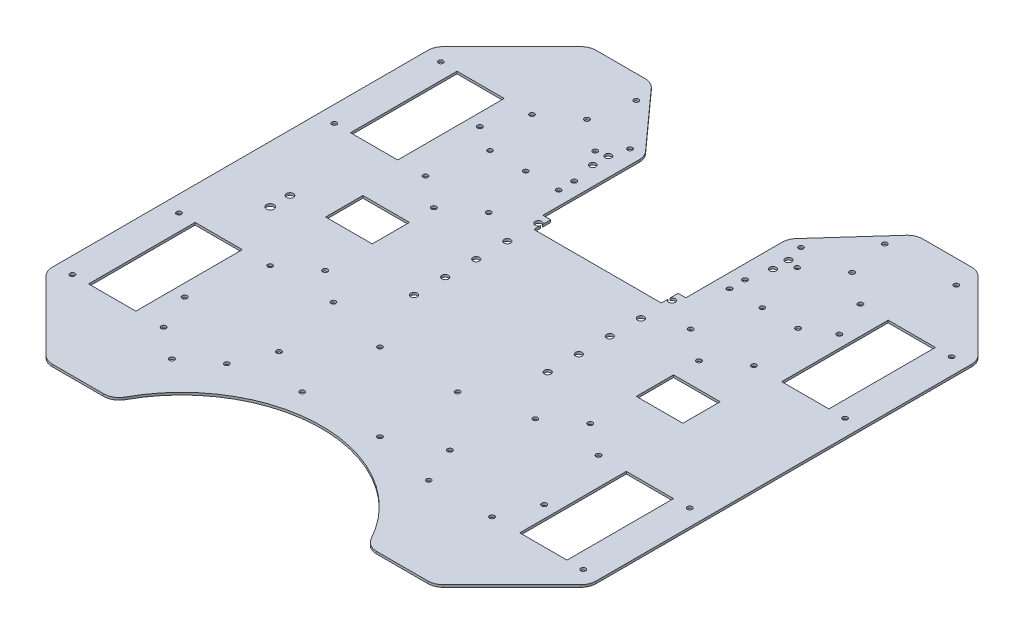
from build123d import *

# Parameters (mm, degrees)
SKETCH_1_R          = 1.55
SKETCH_1_W          = 30.4
SKETCH_1_H          = 68.58
SKETCH_1_R_2        = 2.5
SKETCH_1_R_3        = 2.205
SKETCH_1_R_4        = 2.05
EXTRUDE_1_DEPTH     = 1.5
FILLET_1_R          = 10
FILLET_2_R          = 10
FILLET_3_R          = 10
SKETCH_2_W          = 80
SKETCH_2_H          = 29.628438218
CUT_EXTRUDE_1_DEPTH = 10
SKETCH_3_W          = 30
SKETCH_3_H          = 24
CUT_EXTRUDE_2_DEPTH = 10
SKETCH_1_4_R        = 2.1
CUT_EXTRUDE_3_DEPTH = 10
SKETCH_5_W          = 92
SKETCH_5_H          = 68.528071536
CUT_EXTRUDE_4_DEPTH = 4
SKETCH_6_W          = 82
SKETCH_6_H          = 10.813051581
CUT_EXTRUDE_5_DEPTH = 10
FILLET_4_R          = 10
SKETCH_1_5_R        = 1.6
CUT_EXTRUDE_7_DEPTH = 10
SKETCH_1_6_R        = 1.6
CUT_EXTRUDE_8_DEPTH = 10


with BuildPart() as part:
    # 草图1 → 凸台-拉伸1 (new body)
    with BuildSketch(Plane(origin=(0, 0, 0), x_dir=(1, 0, 0), z_dir=(0, 1, 0))):
        with BuildLine():
            Line((-85, 175), (-125, 175))
            Line((-125, 175), (-175, 125))
            Line((-175, 125), (-175, -125))
            Line((-175, -125), (-125, -175))
            Line((-125, -175), (-81.710313025, -175))
            ThreePointArc((-81.710313025, -175), (0, -122.728301649), (81.710313025, -175))
            Line((81.710313025, -175), (125, -175))
            Line((125, -175), (175, -125))
            Line((175, -125), (175, 125))
            Line((175, 125), (125, 175))
            Line((125, 175), (85, 175))
            Line((85, 175), (40, 125))
            Line((40, 125), (40, 85))
            Line((40, 85), (-40, 85))
            Line((-40, 85), (-40, 125))
            Line((-40, 125), (-85, 175))
        make_face()
        with Locations((-164.434, -118.58)):
            Circle(SKETCH_1_R, mode=Mode.SUBTRACT)
        with Locations((-105.72, -118.58)):
            Circle(SKETCH_1_R, mode=Mode.SUBTRACT)
        with Locations((-65, -118.58)):
            Circle(SKETCH_1_R, mode=Mode.SUBTRACT)
        with Locations((-25, -110)):
            Circle(SKETCH_1_R, mode=Mode.SUBTRACT)
        with Locations((-138.794, -84.29)):
            Rectangle(SKETCH_1_W, SKETCH_1_H, mode=Mode.SUBTRACT)
        with Locations((-164.434, -50)):
            Circle(SKETCH_1_R, mode=Mode.SUBTRACT)
        with Locations((-105.72, -50)):
            Circle(SKETCH_1_R, mode=Mode.SUBTRACT)
        with Locations((-138.472923085, -17.157455951)):
            Circle(SKETCH_1_R_2, mode=Mode.SUBTRACT)
        with Locations((-138.472923085, -4.457455951)):
            Circle(SKETCH_1_R_3, mode=Mode.SUBTRACT)
        with Locations((-65, -50)):
            Circle(SKETCH_1_R, mode=Mode.SUBTRACT)
        with Locations((-25, -60)):
            Circle(SKETCH_1_R, mode=Mode.SUBTRACT)
        with Locations((25, -110)):
            Circle(SKETCH_1_R, mode=Mode.SUBTRACT)
        with Locations((65, -118.58)):
            Circle(SKETCH_1_R, mode=Mode.SUBTRACT)
        with Locations((105.72, -118.58)):
            Circle(SKETCH_1_R, mode=Mode.SUBTRACT)
        with Locations((164.434, -118.58)):
            Circle(SKETCH_1_R, mode=Mode.SUBTRACT)
        with Locations((25, -60)):
            Circle(SKETCH_1_R, mode=Mode.SUBTRACT)
        with Locations((65, -50)):
            Circle(SKETCH_1_R, mode=Mode.SUBTRACT)
        with Locations((105.72, -50)):
            Circle(SKETCH_1_R, mode=Mode.SUBTRACT)
        with Locations((138.794, -84.29)):
            Rectangle(SKETCH_1_W, SKETCH_1_H, mode=Mode.SUBTRACT)
        with Locations((164.434, -50)):
            Circle(SKETCH_1_R, mode=Mode.SUBTRACT)
        with Locations((-164.434, 50)):
            Circle(SKETCH_1_R, mode=Mode.SUBTRACT)
        with Locations((-138.794, 84.29)):
            Rectangle(SKETCH_1_W, SKETCH_1_H, mode=Mode.SUBTRACT)
        with Locations((-105.72, 50)):
            Circle(SKETCH_1_R, mode=Mode.SUBTRACT)
        with Locations((-99.147504451, 85)):
            Circle(SKETCH_1_R, mode=Mode.SUBTRACT)
        with Locations((-65, 50)):
            Circle(SKETCH_1_R, mode=Mode.SUBTRACT)
        with Locations((-76.13554325, 85)):
            Circle(SKETCH_1_R, mode=Mode.SUBTRACT)
        with Locations((-55, 85)):
            Circle(SKETCH_1_R, mode=Mode.SUBTRACT)
        with Locations((-164.434, 118.58)):
            Circle(SKETCH_1_R, mode=Mode.SUBTRACT)
        with Locations((-105.72, 118.58)):
            Circle(SKETCH_1_R, mode=Mode.SUBTRACT)
        with Locations((-58, 110)):
            Circle(SKETCH_1_R_4, mode=Mode.SUBTRACT)
        with Locations((-65, 118.58)):
            Circle(SKETCH_1_R, mode=Mode.SUBTRACT)
        with Locations((-58, 120)):
            Circle(SKETCH_1_R_4, mode=Mode.SUBTRACT)
        with Locations((-55, 131)):
            Circle(SKETCH_1_R, mode=Mode.SUBTRACT)
        with Locations((-43, 110)):
            Circle(SKETCH_1_R_4, mode=Mode.SUBTRACT)
        with Locations((-43, 120)):
            Circle(SKETCH_1_R_4, mode=Mode.SUBTRACT)
        with Locations((-80, 160)):
            Circle(SKETCH_1_R, mode=Mode.SUBTRACT)
        with Locations((65, 50)):
            Circle(SKETCH_1_R, mode=Mode.SUBTRACT)
        with Locations((55, 85)):
            Circle(SKETCH_1_R, mode=Mode.SUBTRACT)
        with Locations((76.13554325, 85)):
            Circle(SKETCH_1_R, mode=Mode.SUBTRACT)
        with Locations((105.72, 50)):
            Circle(SKETCH_1_R, mode=Mode.SUBTRACT)
        with Locations((99.147504451, 85)):
            Circle(SKETCH_1_R, mode=Mode.SUBTRACT)
        with Locations((164.434, 50)):
            Circle(SKETCH_1_R, mode=Mode.SUBTRACT)
        with Locations((138.794, 84.29)):
            Rectangle(SKETCH_1_W, SKETCH_1_H, mode=Mode.SUBTRACT)
        with Locations((43, 110)):
            Circle(SKETCH_1_R_4, mode=Mode.SUBTRACT)
        with Locations((43, 120)):
            Circle(SKETCH_1_R_4, mode=Mode.SUBTRACT)
        with Locations((58, 110)):
            Circle(SKETCH_1_R_4, mode=Mode.SUBTRACT)
        with Locations((58, 120)):
            Circle(SKETCH_1_R_4, mode=Mode.SUBTRACT)
        with Locations((65, 118.58)):
            Circle(SKETCH_1_R, mode=Mode.SUBTRACT)
        with Locations((55, 131)):
            Circle(SKETCH_1_R, mode=Mode.SUBTRACT)
        with Locations((80, 160)):
            Circle(SKETCH_1_R, mode=Mode.SUBTRACT)
        with Locations((105.72, 118.58)):
            Circle(SKETCH_1_R, mode=Mode.SUBTRACT)
        with Locations((164.434, 118.58)):
            Circle(SKETCH_1_R, mode=Mode.SUBTRACT)
        with Locations((126, 160)):
            Circle(SKETCH_1_R, mode=Mode.SUBTRACT)
    extrude(amount=EXTRUDE_1_DEPTH)

    # 圆角1
    fillet_1_edges = [part.edges().sort_by_distance(p)[0] for p in [
        (-40, 0.75, -125),
    ]]
    fillet(fillet_1_edges, radius=FILLET_1_R)

    # 圆角2
    fillet_2_edges = [part.edges().sort_by_distance(p)[0] for p in [
        (40, 0.75, -125),
    ]]
    fillet(fillet_2_edges, radius=FILLET_2_R)

    # 圆角3
    fillet_3_edges = [part.edges().sort_by_distance(p)[0] for p in [
        (-85, 0.75, -175),
        (85, 0.75, -175),
        (125, 0.75, -175),
        (175, 0.75, -125),
        (175, 0.75, 125),
        (125, 0.75, 175),
        (81.710313025, 0.75, 175),
        (-81.710313025, 0.75, 175),
        (-125, 0.75, 175),
        (-175, 0.75, 125),
        (-175, 0.75, -125),
        (-125, 0.75, -175),
    ]]
    fillet(fillet_3_edges, radius=FILLET_3_R)

    # 草图2 → 切除-拉伸1 (cut)
    with BuildSketch(Plane(origin=(0, 1.5, 0), x_dir=(1, 0, 0), z_dir=(0, 1, 0))):
        with Locations((0, 70.185780891)):
            Rectangle(SKETCH_2_W, SKETCH_2_H)
    extrude(amount=-CUT_EXTRUDE_1_DEPTH, mode=Mode.SUBTRACT)

    # 草图3 → 切除-拉伸2 (cut)
    with BuildSketch(Plane(origin=(0, 1.5, 0), x_dir=(1, 0, 0), z_dir=(0, 1, 0))):
        with Locations((-100, 7)):
            Rectangle(SKETCH_3_W, SKETCH_3_H)
        with Locations((100, 7)):
            Rectangle(SKETCH_3_W, SKETCH_3_H)
    extrude(amount=-CUT_EXTRUDE_2_DEPTH, mode=Mode.SUBTRACT)

    # 草图1<4> → 切除-拉伸3 (cut)
    with BuildSketch(Plane(origin=(0, 0, 0), x_dir=(1, 0, 0), z_dir=(0, 1, 0))):
        with Locations((43, -20)):
            Circle(SKETCH_1_4_R)
        with Locations((43, 0)):
            Circle(SKETCH_1_4_R)
        with Locations((43, 20)):
            Circle(SKETCH_1_4_R)
        with Locations((43, 40)):
            Circle(SKETCH_1_4_R)
        with Locations((43, 60)):
            Circle(SKETCH_1_4_R)
        with Locations((-43, -20)):
            Circle(SKETCH_1_4_R)
        with Locations((-43, 0)):
            Circle(SKETCH_1_4_R)
        with Locations((-43, 20)):
            Circle(SKETCH_1_4_R)
        with Locations((-43, 40)):
            Circle(SKETCH_1_4_R)
        with Locations((-43, 60)):
            Circle(SKETCH_1_4_R)
    extrude(amount=CUT_EXTRUDE_3_DEPTH, mode=Mode.SUBTRACT)

    # 草图5 → 切除-拉伸4 (cut)
    with BuildSketch(Plane.XZ):
        with Locations((0, -100.191724722)):
            Rectangle(SKETCH_5_W, SKETCH_5_H)
    extrude(amount=-CUT_EXTRUDE_4_DEPTH, mode=Mode.SUBTRACT)

    # 草图6 → 切除-拉伸5 (cut)
    with BuildSketch(Plane(origin=(0, 1.5, 0), x_dir=(1, 0, 0), z_dir=(0, 1, 0))):
        with Locations((0, 60.521163164)):
            Rectangle(SKETCH_6_W, SKETCH_6_H)
    extrude(amount=-CUT_EXTRUDE_5_DEPTH, mode=Mode.SUBTRACT)

    # 圆角4
    fillet_4_edges = [part.edges().sort_by_distance(p)[0] for p in [
        (46, 0.75, -131.666666667),
        (-46, 0.75, -131.666666667),
    ]]
    fillet(fillet_4_edges, radius=FILLET_4_R)

    # 草图1<5> → 切除-拉伸7 (cut)
    with BuildSketch(Plane(origin=(0, 0, 0), x_dir=(1, 0, 0), z_dir=(0, 1, 0))):
        with Locations((-85.36, -35)):
            Circle(SKETCH_1_5_R)
        with Locations((-85.36, -133.58)):
            Circle(SKETCH_1_5_R)
        with Locations((-115.72, -95)):
            Circle(SKETCH_1_5_R)
        with Locations((55, -95)):
            Circle(SKETCH_1_5_R)
        with Locations((115.72, -95)):
            Circle(SKETCH_1_5_R)
        with Locations((85.36, -35)):
            Circle(SKETCH_1_5_R)
        with Locations((85.36, 133.58)):
            Circle(SKETCH_1_5_R)
        with Locations((115.72, 95)):
            Circle(SKETCH_1_5_R)
        with Locations((55, 95)):
            Circle(SKETCH_1_5_R)
        with Locations((85.36, 35)):
            Circle(SKETCH_1_5_R)
        with Locations((-85.36, 35)):
            Circle(SKETCH_1_5_R)
        with Locations((-55, 95)):
            Circle(SKETCH_1_5_R)
        with Locations((-115.72, 95)):
            Circle(SKETCH_1_5_R)
        with Locations((-85.36, 133.58)):
            Circle(SKETCH_1_5_R)
    extrude(amount=CUT_EXTRUDE_7_DEPTH, mode=Mode.SUBTRACT)

    # 草图1<6> → 切除-拉伸8 (cut)
    with BuildSketch(Plane(origin=(0, 0, 0), x_dir=(1, 0, 0), z_dir=(0, 1, 0))):
        with Locations((-55, -95)):
            Circle(SKETCH_1_6_R)
    extrude(amount=CUT_EXTRUDE_8_DEPTH, mode=Mode.SUBTRACT)


solid = part.part
